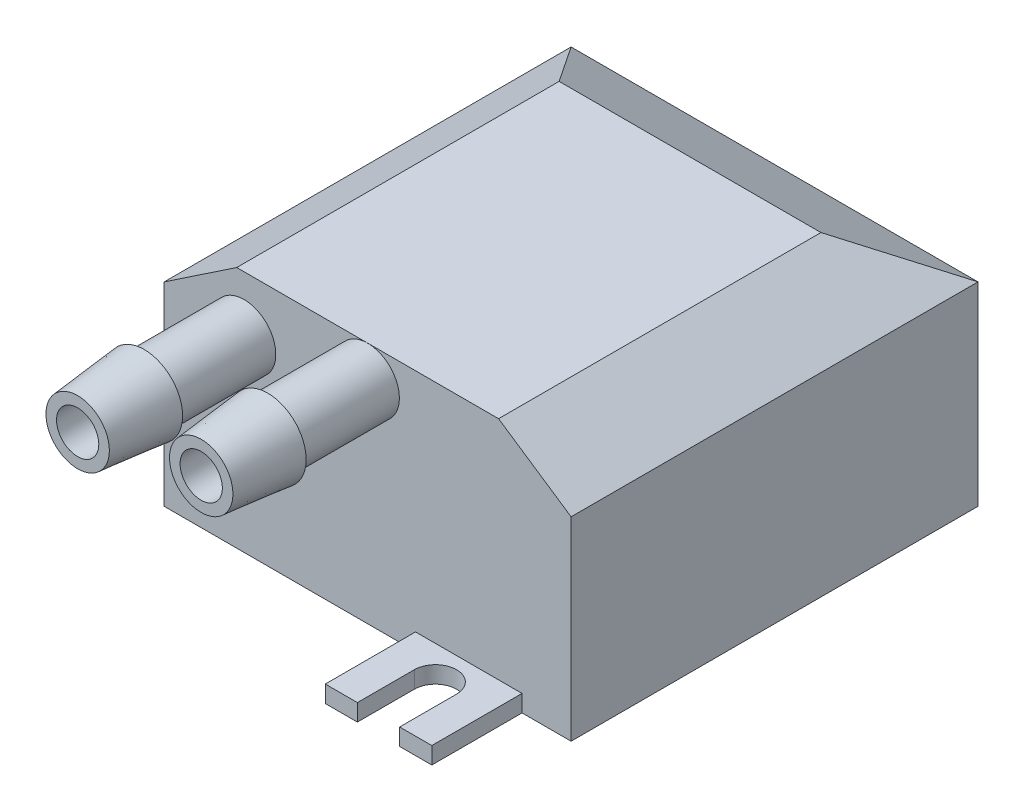
from build123d import *

# Parameters (mm, degrees)
SKETCH1_W          = 61.11875
SKETCH1_H          = 61.11875
EXTRUDE1_DEPTH     = 36.5125
SKETCH3_OUTSIDE_W  = 81.884
SKETCH3_OUTSIDE_H  = 57.278
CUT_EXTRUDE7_DEPTH = 62
SKETCH4_OUTSIDE_W  = 81.884
SKETCH4_OUTSIDE_H  = 57.278
CUT_EXTRUDE8_DEPTH = 250
SKETCH2_R          = 4.7625
SKETCH2_R_2        = 3.175
EXTRUDE2_DEPTH     = 25
SKETCH5_R          = 4.7625
SKETCH5_R_2        = 3.175
EXTRUDE3_DEPTH     = 25
EXTRUDE4_DEPTH     = 2.54
SKETCH7_R          = 5.76
SKETCH7_R_2        = 4.7625
EXTRUDE5_DEPTH     = 10


with BuildPart() as part:
    # Sketch1 → Extrude1 (new body)
    with BuildSketch(Plane(origin=(0, 0, 0), x_dir=(1, 0, 0), z_dir=(0, 1, 0))):
        Rectangle(SKETCH1_W, SKETCH1_H)
    extrude(amount=EXTRUDE1_DEPTH)

    # Sketch3 outside → Cut-Extrude7 (cut)
    with BuildSketch(Plane.XY.offset(30.559375)):
        with Locations((0, 18.256)):
            Rectangle(SKETCH3_OUTSIDE_W, SKETCH3_OUTSIDE_H)
        Polygon((19.664807265, 36.5125), (30.559375, 29.197130008), (30.559375, 0), (-30.559375, 0), (-30.559375, 29.197130008), (-19.664807265, 36.5125), align=None, mode=Mode.SUBTRACT)
    extrude(amount=-CUT_EXTRUDE7_DEPTH, mode=Mode.SUBTRACT)

    # Sketch4 outside → Cut-Extrude8 (cut)
    with BuildSketch(Plane(origin=(30.559375, 0, 0), x_dir=(0, 0, -1), z_dir=(1, 0, 0))):
        with Locations((0, 18.256)):
            Rectangle(SKETCH4_OUTSIDE_W, SKETCH4_OUTSIDE_H)
        Polygon((-30.559375, 36.5125), (17.867202311, 36.5125), (30.559375, 29.197130008), (30.559375, 0), (-30.559375, 0), align=None, mode=Mode.SUBTRACT)
    extrude(amount=-CUT_EXTRUDE8_DEPTH, mode=Mode.SUBTRACT)

    # Sketch2 → Extrude2 (add)
    with BuildSketch(Plane.XY.offset(30.559375)):
        with Locations((0, 31.741283107)):
            Circle(SKETCH2_R)
        with Locations((0, 31.741283107)):
            Circle(SKETCH2_R_2, mode=Mode.SUBTRACT)
    extrude(amount=EXTRUDE2_DEPTH)

    # Sketch5 → Extrude3 (add)
    with BuildSketch(Plane.XY.offset(30.559375)):
        with Locations((-18.559375, 28.142983961)):
            Circle(SKETCH5_R)
        with Locations((-18.559375, 28.142983961)):
            Circle(SKETCH5_R_2, mode=Mode.SUBTRACT)
    extrude(amount=EXTRUDE3_DEPTH)

    # Sketch6 → Extrude4 (add)
    with BuildSketch(Plane.XZ):
        with BuildLine():
            Line((7.191375, 30.559375), (23.193375, 30.559375))
            Line((23.193375, 30.559375), (23.193375, 44.116625))
            Line((23.193375, 44.116625), (18.367375, 44.116625))
            Line((18.367375, 44.116625), (18.367375, 35.564523256))
            ThreePointArc((18.367375, 35.564523256), (15.192375, 32.389523256), (12.017375, 35.564523256))
            Line((12.017375, 35.564523256), (12.017375, 44.116625))
            Line((12.017375, 44.116625), (7.191375, 44.116625))
            Line((7.191375, 44.116625), (7.191375, 30.559375))
        make_face()
    extrude(amount=-EXTRUDE4_DEPTH)

    # Sketch7 → Extrude5 (add)
    with BuildSketch(Plane.XY.offset(55.559375)):
        with Locations((0, 31.741283107)):
            Circle(SKETCH7_R)
        with Locations((0, 31.741283107)):
            Circle(SKETCH7_R_2, mode=Mode.SUBTRACT)
    extrude(amount=-EXTRUDE5_DEPTH)

    # Sketch8 → Cut-Revolve2 (revolve, cut)
    with BuildSketch(Plane(origin=(0, 0, 0), x_dir=(0, 0, -1), z_dir=(1, 0, 0))):
        Polygon((-55.559375, 36.503783107), (-55.559375, 37.501283107), (-45.559375, 37.501283107), align=None)
    revolve(axis=Axis((0, 31.741283107, 55.559375), (0, 0, -1)), mode=Mode.SUBTRACT)

    # Sketch10 → Revolve1 (revolve)
    with BuildSketch(Plane(origin=(-18.559375, 0, 0), x_dir=(0, 0, -1), z_dir=(1, 0, 0))):
        Polygon((-55.559375, 32.905483961), (-45.559375, 32.905483961), (-45.559375, 33.905483961), align=None)
    revolve(axis=Axis((-18.559375, 28.142983961, 55.559375), (0, 0, -1)))


solid = part.part
